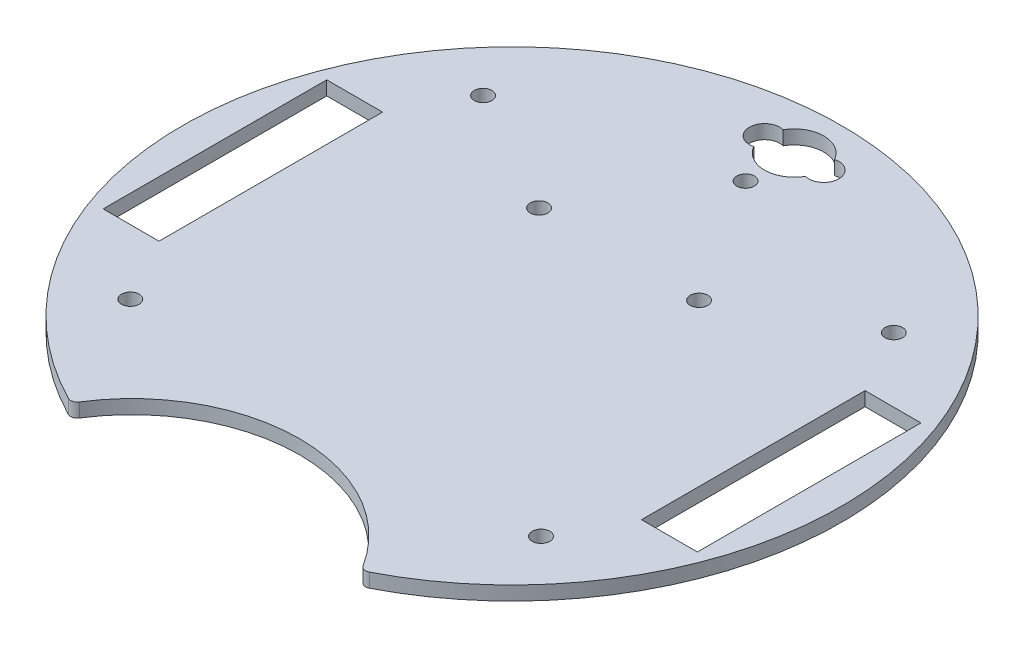
from build123d import *

# Parameters (mm, degrees)
SKETCH1_R           = 2
SKETCH1_W           = 12.7
SKETCH1_H           = 50.8
BOSS_EXTRUDE3_DEPTH = 3.175


with BuildPart() as part:
    # Sketch1 → Boss-Extrude3 (new body)
    with BuildSketch(Plane(origin=(0, 0, 0), x_dir=(1, 0, 0), z_dir=(0, 1, 0))):
        with BuildLine():
            ThreePointArc((34.194833578, -66.63583839), (33.11372382, -66.748004461), (32.240681933, -66.10056535))
            ThreePointArc((32.240681933, -66.10056535), (0, -48.302004425), (-32.240681933, -66.10056535))
            ThreePointArc((-32.240681933, -66.10056535), (-33.11372382, -66.748004461), (-34.194833578, -66.63583839))
            ThreePointArc((-34.194833578, -66.63583839), (0, 74.897407173), (34.194833578, -66.63583839))
        make_face()
        with Locations((0, 53.061187965)):
            Circle(SKETCH1_R, mode=Mode.SUBTRACT)
        with Locations((18.178952795, 24.310551096)):
            Circle(SKETCH1_R, mode=Mode.SUBTRACT)
        with Locations((46.663733983, 40.081231883)):
            Circle(SKETCH1_R, mode=Mode.SUBTRACT)
        with Locations((46.663733983, -40.081231883)):
            Circle(SKETCH1_R, mode=Mode.SUBTRACT)
        with Locations((-46.663733983, -40.081231883)):
            Circle(SKETCH1_R, mode=Mode.SUBTRACT)
        with Locations((-18.178952795, 24.310551096)):
            Circle(SKETCH1_R, mode=Mode.SUBTRACT)
        with Locations((-46.663733983, 40.081231883)):
            Circle(SKETCH1_R, mode=Mode.SUBTRACT)
        with Locations((61.164123727, 0)):
            Rectangle(SKETCH1_W, SKETCH1_H, mode=Mode.SUBTRACT)
        with Locations((-61.164123727, 0)):
            Rectangle(SKETCH1_W, SKETCH1_H, mode=Mode.SUBTRACT)
        with BuildLine():
            ThreePointArc((-5.853899988, 60.78531778), (0.003726822, 57.376699875), (5.857575472, 60.791802193))
            ThreePointArc((5.857575472, 60.791802193), (10.16, 64.107698843), (5.857575472, 67.423595493))
            ThreePointArc((5.857575472, 67.423595493), (0.003726822, 70.838697812), (-5.853899988, 67.430079907))
            ThreePointArc((-5.853899988, 67.430079907), (-10.167207264, 64.107698843), (-5.853899988, 60.78531778))
        make_face(mode=Mode.SUBTRACT)
    extrude(amount=BOSS_EXTRUDE3_DEPTH)


solid = part.part
